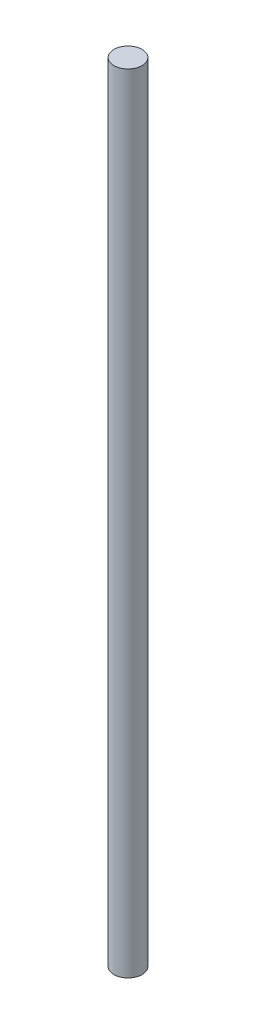
from build123d import *

# Parameters (mm, degrees)
SKETCH1_R           = 1.5
BOSS_EXTRUDE1_DEPTH = 84


with BuildPart() as part:
    # Sketch1 → Boss-Extrude1 (new body)
    with BuildSketch(Plane(origin=(0, 0, 0), x_dir=(1, 0, 0), z_dir=(0, 1, 0))):
        Circle(SKETCH1_R)
    extrude(amount=BOSS_EXTRUDE1_DEPTH)


solid = part.part
